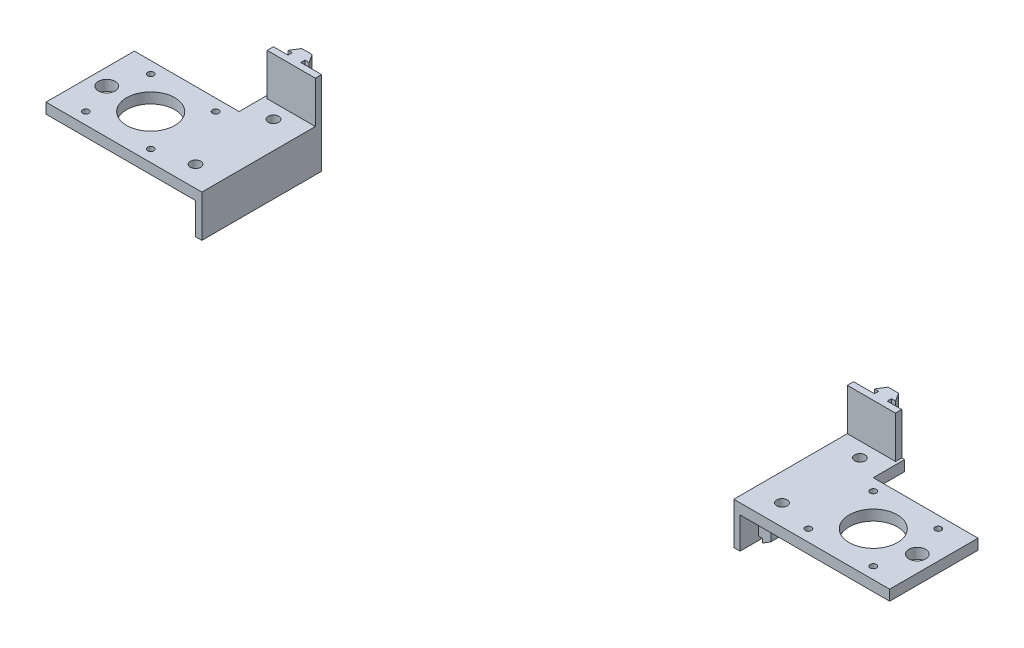
from build123d import *

# Parameters (mm, degrees)
SKETCH1_R           = 2.5
SKETCH1_R_2         = 1.5
SKETCH1_R_3         = 4
SKETCH1_R_4         = 11.5
BOSS_EXTRUDE1_DEPTH = 5
SKETCH2_W           = 57.2
SKETCH2_H           = 23
BOSS_EXTRUDE2_DEPTH = 3
BOSS_EXTRUDE3_START = -8.5
BOSS_EXTRUDE3_DEPTH = 40
SKETCH5_W           = 3
SKETCH5_H           = 3
CUT_EXTRUDE1_DEPTH  = 58.2
SKETCH6_W           = 23
SKETCH6_H           = 20
BOSS_EXTRUDE4_DEPTH = 3
BOSS_EXTRUDE5_START = -25
BOSS_EXTRUDE5_DEPTH = 25


with BuildPart() as part:
    # Sketch1 → Boss-Extrude1 (new body)
    with BuildSketch(Plane(origin=(0, 0, 0), x_dir=(1, 0, 0), z_dir=(0, 1, 0))):
        Polygon((42.5, 36.1), (21.1, 36.1), (21.1, 21.1), (21.1, -21.1), (42.5, -21.1), align=None)
        with Locations((32.5, -11.1)):
            Circle(SKETCH1_R, mode=Mode.SUBTRACT)
        with Locations((32.5, 26.1)):
            Circle(SKETCH1_R, mode=Mode.SUBTRACT)
        Polygon((-21.1, -21.1), (21.1, -21.1), (21.1, 21.1), (-21.1, 21.1), (-28.9, 21.1), (-28.9, -21.1), align=None)
        with Locations((-15.5, -15.5)):
            Circle(SKETCH1_R_2, mode=Mode.SUBTRACT)
        with Locations((-21, 0)):
            Circle(SKETCH1_R_3, mode=Mode.SUBTRACT)
        Circle(SKETCH1_R_4, mode=Mode.SUBTRACT)
        with Locations((15.5, -15.5)):
            Circle(SKETCH1_R_2, mode=Mode.SUBTRACT)
        with Locations((-15.5, 15.5)):
            Circle(SKETCH1_R_2, mode=Mode.SUBTRACT)
        with Locations((15.5, 15.5)):
            Circle(SKETCH1_R_2, mode=Mode.SUBTRACT)
    extrude(amount=BOSS_EXTRUDE1_DEPTH)

    # Sketch2 → Boss-Extrude2 (add)
    with BuildSketch(Plane(origin=(42.5, 0, 0), x_dir=(0, 0, -1), z_dir=(1, 0, 0))):
        with Locations((7.5, -6.5)):
            Rectangle(SKETCH2_W, SKETCH2_H)
    extrude(amount=BOSS_EXTRUDE2_DEPTH)

    # Sketch4 → Boss-Extrude3 (add)
    with BuildSketch(Plane(origin=(0, 0, -36.1), x_dir=(-1, 0, 0), z_dir=(0, 0, -1)).offset(BOSS_EXTRUDE3_START)):
        Polygon((-36.5, -7.5), (-40.5, -5), (-40.5, -6.95), (-42.5, -4.95), (-42.5, -13.05), (-40.5, -13.05), (-40.5, -15), (-36.5, -12.5), align=None)
    extrude(amount=-BOSS_EXTRUDE3_DEPTH)

    # Sketch5 → Cut-Extrude1 (cut, through all)
    with BuildSketch(Plane.XY.offset(21.1)):
        with Locations((44, -16.5)):
            Rectangle(SKETCH5_W, SKETCH5_H)
    extrude(amount=-CUT_EXTRUDE1_DEPTH, mode=Mode.SUBTRACT)

    # Sketch6 → Boss-Extrude4 (add)
    with BuildSketch(Plane(origin=(0, 0, -36.1), x_dir=(-1, 0, 0), z_dir=(0, 0, -1))):
        with Locations((-34, 15)):
            Rectangle(SKETCH6_W, SKETCH6_H)
    extrude(amount=-BOSS_EXTRUDE4_DEPTH)

    # Sketch7 → Boss-Extrude5 (add)
    with BuildSketch(Plane(origin=(0, 25, 0), x_dir=(1, 0, 0), z_dir=(0, 1, 0)).offset(BOSS_EXTRUDE5_START)):
        Polygon((35, 42.1), (30, 42.1), (27.5, 38.1), (29.45, 38.1), (29.45, 36.1), (32.5, 36.1), (35.55, 36.1), (35.55, 38.1), (37.5, 38.1), align=None)
    extrude(amount=BOSS_EXTRUDE5_DEPTH)


with BuildPart() as body_2:
    # Mirror1: mirrored copy
    add(part.part.mirror(Plane.ZY.offset(-172.5)))


solid = Compound([part.part, body_2.part])
